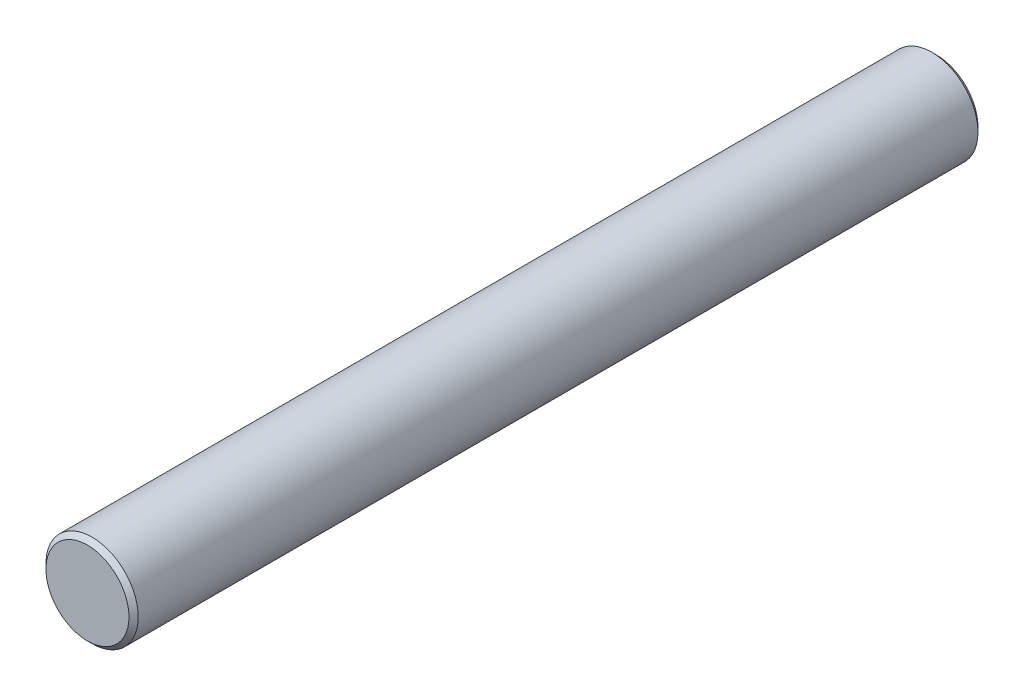
from build123d import *

# Parameters (mm, degrees)
SCHIZZO1_R                   = 2.5
ESTRUSIONE_ESTRUSIONE1_DEPTH = 46
SMUSSO1_SIZE                 = 0.25


with BuildPart() as part:
    # Schizzo1 → Estrusione-Estrusione1 (new body)
    with BuildSketch(Plane.XY):
        Circle(SCHIZZO1_R)
    extrude(amount=ESTRUSIONE_ESTRUSIONE1_DEPTH)

    # Smusso1
    smusso1_edges = [part.edges().sort_by_distance(p)[0] for p in [
        (-2.5, 0, 0),
        (-2.5, 0, 46),
    ]]
    chamfer(smusso1_edges, length=SMUSSO1_SIZE)


solid = part.part
